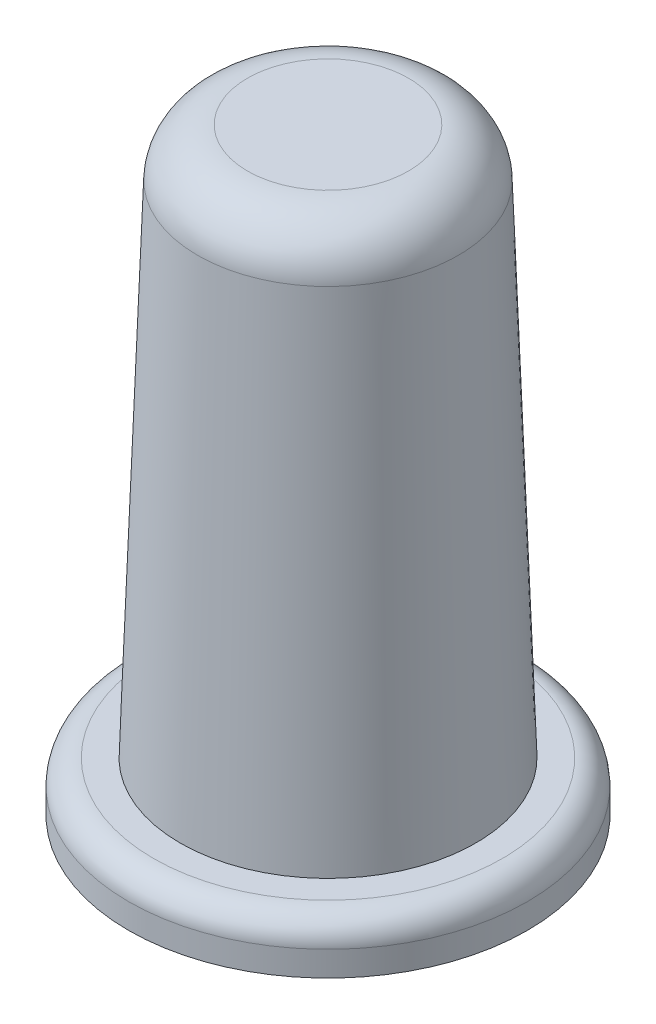
from build123d import *

# Parameters (mm, degrees)
SKETCH1_R           = 38.1
BOSS_EXTRUDE1_DEPTH = 152.4
BOSS_EXTRUDE1_TAPER = 2
FILLET1_R           = 12.7
SKETCH2_R           = 50.8
BOSS_EXTRUDE2_DEPTH = 12.7
FILLET2_R           = 6.35


with BuildPart() as part:
    # Sketch1 → Boss-Extrude1 (new body)
    with BuildSketch(Plane(origin=(0, 0, 0), x_dir=(1, 0, 0), z_dir=(0, 1, 0))):
        Circle(SKETCH1_R)
    extrude(amount=BOSS_EXTRUDE1_DEPTH, taper=BOSS_EXTRUDE1_TAPER)

    # Fillet1
    fillet1_edges = [part.edges().sort_by_distance(p)[0] for p in [
        (-32.778074729, 152.4, 0),
    ]]
    fillet(fillet1_edges, radius=FILLET1_R)

    # Sketch2 → Boss-Extrude2 (add)
    with BuildSketch(Plane(origin=(0, 0, 0), x_dir=(1, 0, 0), z_dir=(0, 1, 0))):
        Circle(SKETCH2_R)
    extrude(amount=BOSS_EXTRUDE2_DEPTH)

    # Fillet2
    fillet2_edges = [part.edges().sort_by_distance(p)[0] for p in [
        (-50.8, 12.7, 0),
    ]]
    fillet(fillet2_edges, radius=FILLET2_R)


solid = part.part
